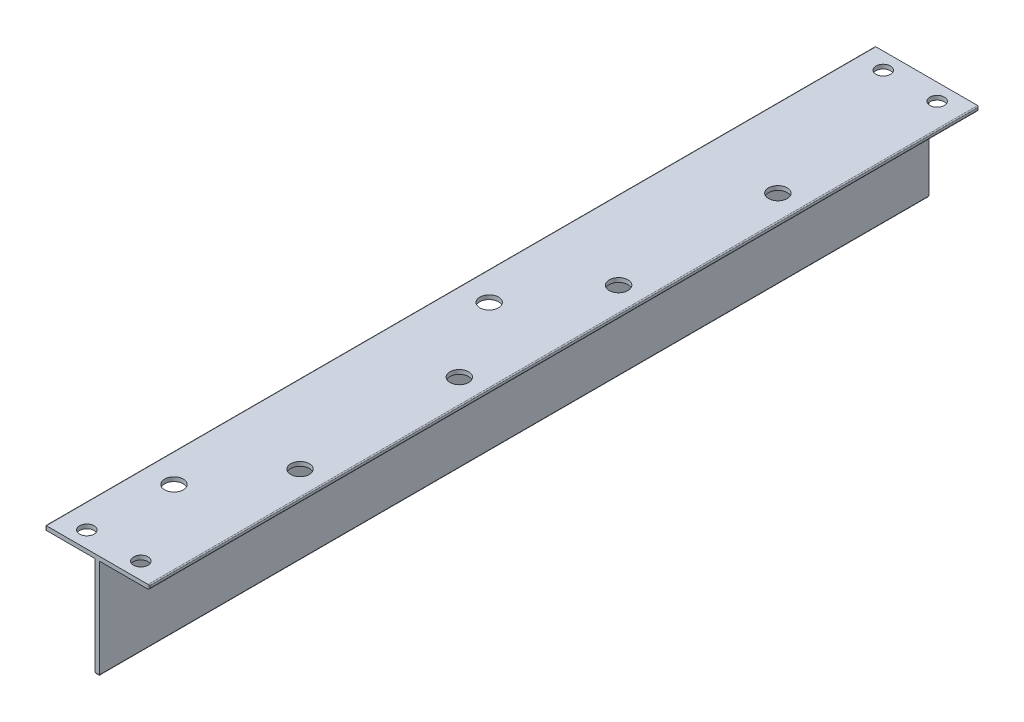
from build123d import *

# Parameters (mm, degrees)
EXTRUDE1_DEPTH                 = 200
FILLET1_R                      = 0.25
F_3_5_3_5_DIAMETER_HOLE1_D     = 3.5
F_4_5_4_5_DIAMETER_HOLE1_D     = 4.5
F_4_5_4_5_DIAMETER_HOLE1_DEPTH = 1
F_4_5_4_5_DIAMETER_HOLE1_TIP   = 1.351936393
LPATTERN1_COUNT                = 4
LPATTERN1_PITCH                = 38.4


with BuildPart() as part:
    # Sketch1 → Extrude1 (new body)
    with BuildSketch(Plane.XY):
        Polygon((0, 0), (0, 24), (-12, 24), (-12, 25), (13, 25), (13, 24), (1, 24), (1, 0), align=None)
    extrude(amount=EXTRUDE1_DEPTH)

    # Fillet1
    fillet1_edges = [part.edges().sort_by_distance(p)[0] for p in [
        (0, 0, 100),
        (-12, 24, 100),
        (-12, 25, 100),
        (13, 24.5, 200),
        (13, 25, 100),
        (13, 24, 100),
        (1, 0, 100),
        (-12, 24.5, 200),
        (0.5, 0, 200),
        (-12, 24.5, 0),
        (13, 24.5, 0),
        (0.5, 0, 0),
    ]]
    fillet(fillet1_edges, radius=FILLET1_R)

    # Ø3.5 (3.5) Diameter Hole1 (through all)
    with Locations(Plane(origin=(-6, 24, 196), x_dir=(-1, 0, 0), z_dir=(0, -1, 0))):
        with Locations((0, 0), (-13, 0), (0, 192), (-13, 192)):
            Hole(F_3_5_3_5_DIAMETER_HOLE1_D / 2)

    # Ø4.5 (4.5) Diameter Hole1
    with Locations(Plane(origin=(-5, 25, 176), x_dir=(0, 0, 1), z_dir=(0, 1, 0))):
        with Locations((0, 0), (-76, 0)):
            Hole(F_4_5_4_5_DIAMETER_HOLE1_D / 2, depth=F_4_5_4_5_DIAMETER_HOLE1_DEPTH)
            with Locations((0, 0, -(F_4_5_4_5_DIAMETER_HOLE1_DEPTH + F_4_5_4_5_DIAMETER_HOLE1_TIP / 2))):  # 118° drill point
                Cone(0, F_4_5_4_5_DIAMETER_HOLE1_D / 2, F_4_5_4_5_DIAMETER_HOLE1_TIP, mode=Mode.SUBTRACT)

    # Sketch10 → Ø4.5 (4.5) Diameter Hole2 (revolve, cut)
    with BuildSketch(Plane(origin=(7, 24, 157.6), x_dir=(0, 0, -1), z_dir=(1, 0, 0))):
        Polygon((0, 0), (0, 2.351936393), (2.25, 1), (2.25, 0), align=None)
    f_4_5_4_5_diameter_hole2 = revolve(axis=Axis((7, 17.65, 157.6), (0, 1, 0)), mode=Mode.SUBTRACT)

    # LPattern1: Ø4.5 (4.5) Diameter Hole2 ×4
    with Locations(*[(0, 0, -i * LPATTERN1_PITCH) for i in range(1, LPATTERN1_COUNT)]):
        add(f_4_5_4_5_diameter_hole2, mode=Mode.SUBTRACT)


solid = part.part
